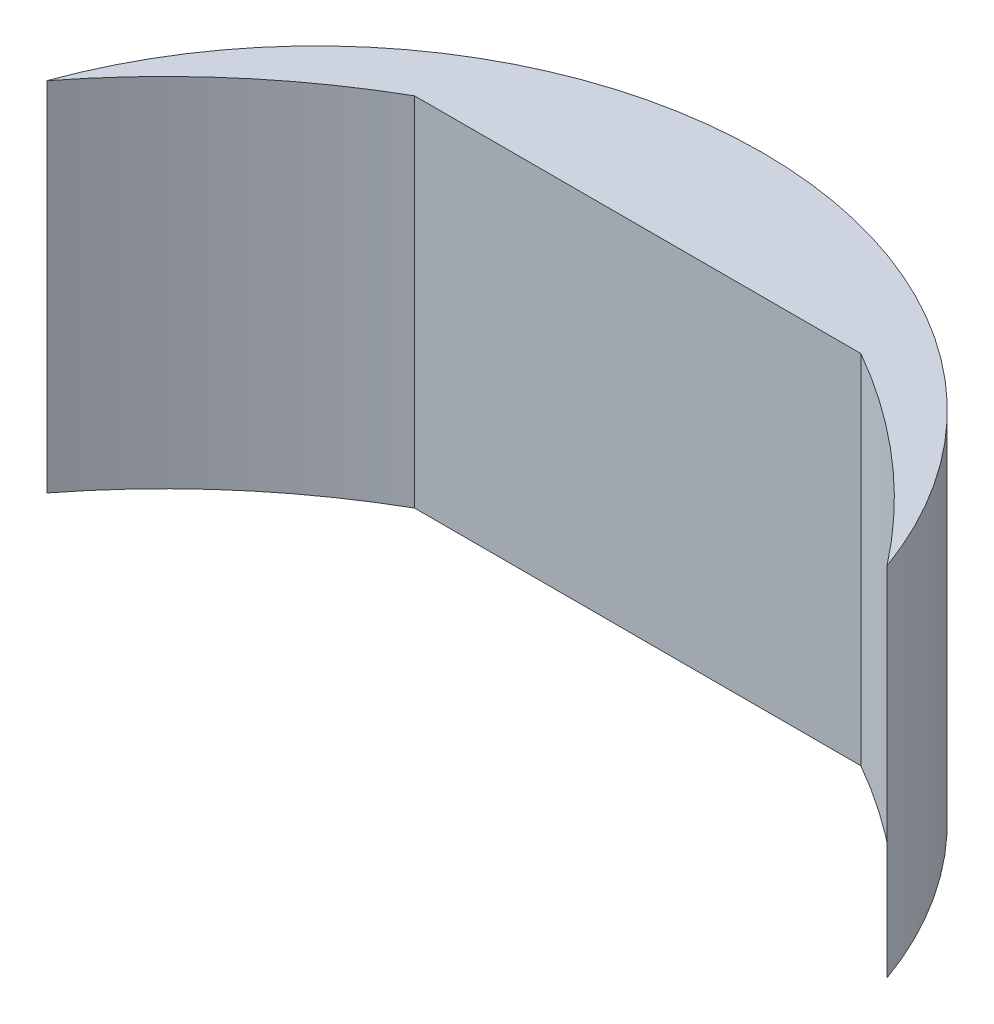
from build123d import *

# Parameters (mm, degrees)
BOSS_EXTRUDE7_DEPTH = 101.6


with BuildPart() as part:
    # Sketch5 → Boss-Extrude7 (new body)
    with BuildSketch(Plane(origin=(0, 0, 0), x_dir=(1, 0, 0), z_dir=(0, 1, 0))):
        with BuildLine():
            Line((0, 0), (127, 0))
            ThreePointArc((127, 0), (157.4024273, -21.53769215), (183.031190425, -48.581106681))
            ThreePointArc((183.031190425, -48.581106681), (63.5, 35.508585518), (-56.031190425, -48.581106681))
            ThreePointArc((-56.031190425, -48.581106681), (-30.4024273, -21.53769215), (0, 0))
        make_face()
    extrude(amount=BOSS_EXTRUDE7_DEPTH)


solid = part.part
